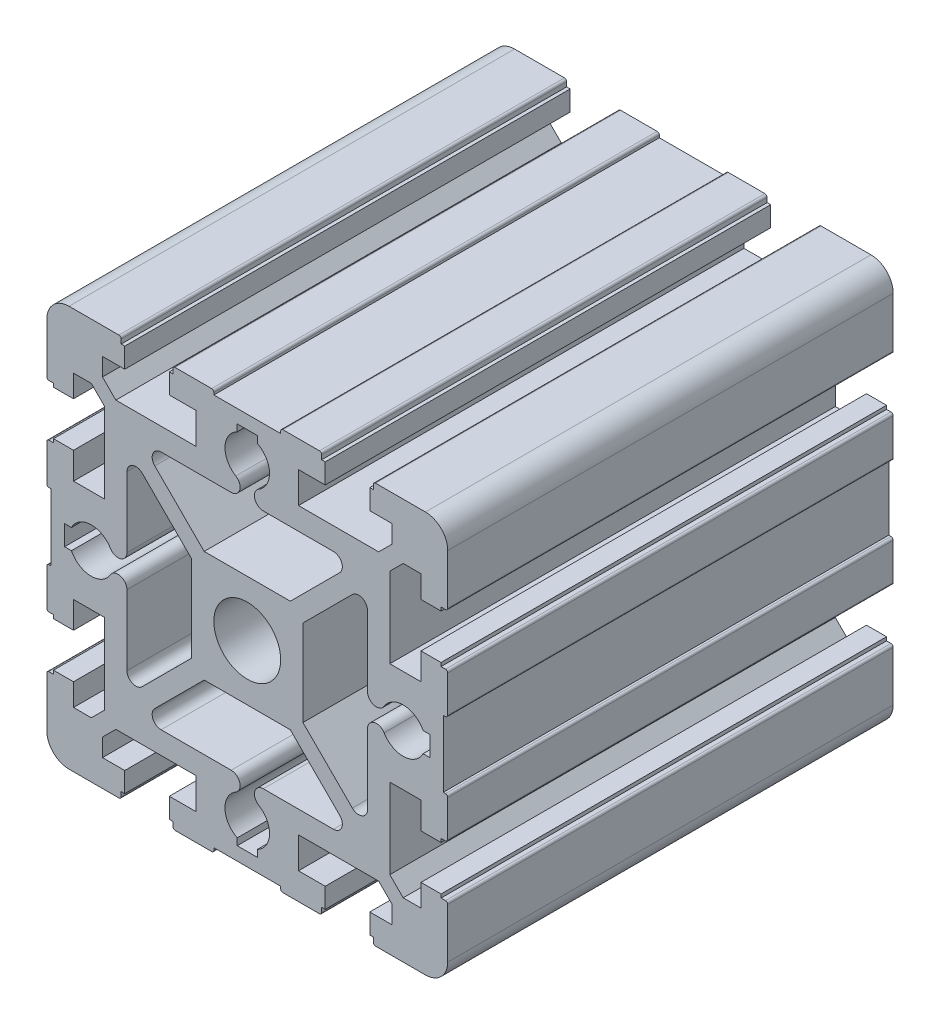
from build123d import *

# Parameters (mm, degrees)
SKETCH1_R          = 7.5
BASE_EXTRUDE_DEPTH = 100


with BuildPart() as part:
    # Sketch1 → Base-Extrude (new body)
    with BuildSketch(Plane.XY):
        with BuildLine():
            Line((16.6998736, -44.500001), (16.6998736, -43.50001))
            Line((16.6998736, -43.50001), (17.499871, -43.50001))
            Line((17.499871, -43.50001), (17.499871, -39.000019))
            Line((17.499871, -39.000019), (11.499883, -39.000019))
            Line((11.499883, -39.000019), (11.499883, -32.000033))
            Line((11.499883, -32.000033), (29.499851, -32.000033))
            Line((29.499851, -32.000033), (32.499845, -35.000027))
            Line((32.499845, -35.000027), (32.499845, -39.000018))
            Line((32.499845, -39.000018), (27.500035, -39.000018))
            Line((27.500035, -39.000018), (27.500035, -43.500009))
            Line((27.500035, -43.500009), (28.3000284, -43.500009))
            Line((28.3000284, -43.500009), (28.3000284, -44.500001))
            ThreePointArc((28.3000284, -44.500001), (28.446474607, -44.853553793), (28.8000274, -45))
            Line((28.8000274, -45), (40.000013735, -45))
            ThreePointArc((40.000013735, -45), (43.535537929, -43.535537929), (45, -40.000013735))
            Line((45, -40.000013735), (45, -28.7999394))
            ThreePointArc((45, -28.7999394), (44.853553793, -28.446386607), (44.500001, -28.2999404))
            Line((44.500001, -28.2999404), (43.500011, -28.2999404))
            Line((43.500011, -28.2999404), (43.500011, -27.499943))
            Line((43.500011, -27.499943), (39.00002, -27.499943))
            Line((39.00002, -27.499943), (39.00002, -32.499933))
            Line((39.00002, -32.499933), (35.000028, -32.499933))
            Line((35.000028, -32.499933), (32.000034, -29.499939))
            Line((32.000034, -29.499939), (32.000034, -11.499973))
            Line((32.000034, -11.499973), (39.00002, -11.499973))
            Line((39.00002, -11.499973), (39.00002, -17.499963))
            Line((39.00002, -17.499963), (43.500011, -17.499963))
            Line((43.500011, -17.499963), (43.500011, -16.6999656))
            Line((43.500011, -16.6999656), (44.500001, -16.6999656))
            ThreePointArc((44.500001, -16.6999656), (44.853553793, -16.553519393), (45, -16.1999666))
            Line((45, -16.1999666), (45, -7.999988))
            ThreePointArc((45, -7.999988), (44.853553793, -7.646435207), (44.500001, -7.499989))
            Line((44.500001, -7.499989), (44.000002, -7.499989))
            Line((44.000002, -7.499989), (44.000002, 7.499981))
            Line((44.000002, 7.499981), (44.500001, 7.499981))
            ThreePointArc((44.500001, 7.499981), (44.853553793, 7.646427207), (45, 7.99998))
            Line((45, 7.99998), (45, 16.1999646))
            ThreePointArc((45, 16.1999646), (44.853553793, 16.553517393), (44.500001, 16.6999636))
            Line((44.500001, 16.6999636), (43.500011, 16.6999636))
            Line((43.500011, 16.6999636), (43.500011, 17.499961))
            Line((43.500011, 17.499961), (39.00002, 17.499961))
            Line((39.00002, 17.499961), (39.00002, 11.499973))
            Line((39.00002, 11.499973), (32.000034, 11.499973))
            Line((32.000034, 11.499973), (32.000034, 29.499941))
            Line((32.000034, 29.499941), (35.000028, 32.499935))
            Line((35.000028, 32.499935), (39.00002, 32.499935))
            Line((39.00002, 32.499935), (39.00002, 27.499945))
            Line((39.00002, 27.499945), (43.500011, 27.499945))
            Line((43.500011, 27.499945), (43.500011, 28.2999384))
            Line((43.500011, 28.2999384), (44.500001, 28.2999384))
            ThreePointArc((44.500001, 28.2999384), (44.853553793, 28.446384607), (45, 28.7999374))
            Line((45, 28.7999374), (45, 40.000013735))
            ThreePointArc((45, 40.000013735), (43.535537929, 43.535537929), (40.000013735, 45))
            Line((40.000013735, 45), (28.8000274, 45))
            ThreePointArc((28.8000274, 45), (28.446474607, 44.853553793), (28.3000284, 44.500001))
            Line((28.3000284, 44.500001), (28.3000284, 43.500003))
            Line((28.3000284, 43.500003), (27.500035, 43.500003))
            Line((27.500035, 43.500003), (27.500035, 39.000012))
            Line((27.500035, 39.000012), (32.499863, 39.000012))
            Line((32.499863, 39.000012), (32.499863, 35.00002))
            Line((32.499863, 35.00002), (29.499869, 32.000026))
            Line((29.499869, 32.000026), (11.499901, 32.000026))
            Line((11.499901, 32.000026), (11.499901, 39.000012))
            Line((11.499901, 39.000012), (17.499893, 39.000012))
            Line((17.499893, 39.000012), (17.499893, 43.500003))
            Line((17.499893, 43.500003), (16.6998916, 43.500003))
            Line((16.6998916, 43.500003), (16.6998916, 44.500001))
            ThreePointArc((16.6998916, 44.500001), (16.553445393, 44.853553793), (16.1998926, 45))
            Line((16.1998926, 45), (7.999916, 45))
            ThreePointArc((7.999916, 45), (7.646363207, 44.853553793), (7.499917, 44.500001))
            Line((7.499917, 44.500001), (7.499917, 44.000002))
            Line((7.499917, 44.000002), (-7.500053, 44.000002))
            Line((-7.500053, 44.000002), (-7.500053, 44.500001))
            ThreePointArc((-7.500053, 44.500001), (-7.646499207, 44.853553793), (-8.000052, 45))
            Line((-8.000052, 45), (-16.2000386, 45))
            ThreePointArc((-16.2000386, 45), (-16.553591393, 44.853553793), (-16.7000376, 44.500001))
            Line((-16.7000376, 44.500001), (-16.7000376, 43.500003))
            Line((-16.7000376, 43.500003), (-17.500035, 43.500003))
            Line((-17.500035, 43.500003), (-17.500035, 39.000012))
            Line((-17.500035, 39.000012), (-11.500065, 39.000012))
            Line((-11.500065, 39.000012), (-11.500065, 32.000026))
            Line((-11.500065, 32.000026), (-29.500031, 32.000026))
            Line((-29.500031, 32.000026), (-32.500025, 35.00002))
            Line((-32.500025, 35.00002), (-32.500025, 39.000012))
            Line((-32.500025, 39.000012), (-27.500035, 39.000012))
            Line((-27.500035, 39.000012), (-27.500035, 43.500003))
            Line((-27.500035, 43.500003), (-28.3000324, 43.500003))
            Line((-28.3000324, 43.500003), (-28.3000324, 44.500001))
            ThreePointArc((-28.3000324, 44.500001), (-28.446478607, 44.853553793), (-28.8000314, 45))
            Line((-28.8000314, 45), (-40.000013735, 45))
            ThreePointArc((-40.000013735, 45), (-43.535537929, 43.535537929), (-45, 40.000013735))
            Line((-45, 40.000013735), (-45, 28.7999374))
            ThreePointArc((-45, 28.7999374), (-44.853553793, 28.446384607), (-44.500001, 28.2999384))
            Line((-44.500001, 28.2999384), (-43.500013, 28.2999384))
            Line((-43.500013, 28.2999384), (-43.500013, 27.499945))
            Line((-43.500013, 27.499945), (-39.000022, 27.499945))
            Line((-39.000022, 27.499945), (-39.000022, 32.499935))
            Line((-39.000022, 32.499935), (-35.00003, 32.499935))
            Line((-35.00003, 32.499935), (-32.000036, 29.499941))
            Line((-32.000036, 29.499941), (-32.000036, 11.499973))
            Line((-32.000036, 11.499973), (-39.000021, 11.499973))
            Line((-39.000021, 11.499973), (-39.000021, 17.499965))
            Line((-39.000021, 17.499965), (-43.500012, 17.499965))
            Line((-43.500012, 17.499965), (-43.500012, 16.6999676))
            Line((-43.500012, 16.6999676), (-44.500001, 16.6999676))
            ThreePointArc((-44.500001, 16.6999676), (-44.853553793, 16.553521393), (-45, 16.1999686))
            Line((-45, 16.1999686), (-45, 7.999984))
            ThreePointArc((-45, 7.999984), (-44.853553793, 7.646431207), (-44.500001, 7.499985))
            Line((-44.500001, 7.499985), (-44.000002, 7.499985))
            Line((-44.000002, 7.499985), (-44.000002, -7.499985))
            Line((-44.000002, -7.499985), (-44.500001, -7.499985))
            ThreePointArc((-44.500001, -7.499985), (-44.853553793, -7.646431207), (-45, -7.999984))
            Line((-45, -7.999984), (-45, -16.1999666))
            ThreePointArc((-45, -16.1999666), (-44.853553793, -16.553519393), (-44.500001, -16.6999656))
            Line((-44.500001, -16.6999656), (-43.500012, -16.6999656))
            Line((-43.500012, -16.6999656), (-43.500012, -17.499963))
            Line((-43.500012, -17.499963), (-39.000021, -17.499963))
            Line((-39.000021, -17.499963), (-39.000021, -11.499973))
            Line((-39.000021, -11.499973), (-32.000034, -11.499973))
            Line((-32.000034, -11.499973), (-32.000034, -29.499939))
            Line((-32.000034, -29.499939), (-35.000028, -32.499933))
            Line((-35.000028, -32.499933), (-39.00002, -32.499933))
            Line((-39.00002, -32.499933), (-39.00002, -27.499943))
            Line((-39.00002, -27.499943), (-43.500011, -27.499943))
            Line((-43.500011, -27.499943), (-43.500011, -28.2999404))
            Line((-43.500011, -28.2999404), (-44.500001, -28.2999404))
            ThreePointArc((-44.500001, -28.2999404), (-44.853553793, -28.446386607), (-45, -28.7999394))
            Line((-45, -28.7999394), (-45, -40.000013735))
            ThreePointArc((-45, -40.000013735), (-43.535537929, -43.535537929), (-40.000013735, -45))
            Line((-40.000013735, -45), (-28.8000294, -45))
            ThreePointArc((-28.8000294, -45), (-28.446476607, -44.853553793), (-28.3000304, -44.500001))
            Line((-28.3000304, -44.500001), (-28.3000304, -43.500011))
            Line((-28.3000304, -43.500011), (-27.500033, -43.500011))
            Line((-27.500033, -43.500011), (-27.500033, -38.999986))
            Line((-27.500033, -38.999986), (-32.500023, -38.999986))
            Line((-32.500023, -38.999986), (-32.500023, -34.999994))
            Line((-32.500023, -34.999994), (-29.500029, -32))
            Line((-29.500029, -32), (-11.500063, -32))
            Line((-11.500063, -32), (-11.500063, -39.000019))
            Line((-11.500063, -39.000019), (-17.500053, -39.000019))
            Line((-17.500053, -39.000019), (-17.500053, -43.50001))
            Line((-17.500053, -43.50001), (-16.7000556, -43.50001))
            Line((-16.7000556, -43.50001), (-16.7000556, -44.500001))
            ThreePointArc((-16.7000556, -44.500001), (-16.553609393, -44.853553793), (-16.2000566, -45))
            Line((-16.2000566, -45), (-8.000074, -45))
            ThreePointArc((-8.000074, -45), (-7.646521207, -44.853553793), (-7.500075, -44.500001))
            Line((-7.500075, -44.500001), (-7.500075, -44.000002))
            Line((-7.500075, -44.000002), (7.499895, -44.000002))
            Line((7.499895, -44.000002), (7.499895, -44.500001))
            ThreePointArc((7.499895, -44.500001), (7.646341207, -44.853553793), (7.999894, -45))
            Line((7.999894, -45), (16.1998746, -45))
            ThreePointArc((16.1998746, -45), (16.553427393, -44.853553793), (16.6998736, -44.500001))
        make_face()
        Circle(SKETCH1_R, mode=Mode.SUBTRACT)
        with BuildLine():
            Line((12.499986, -9.671543771), (23.585745828, -20.7573136))
            ThreePointArc((23.585745828, -20.7573136), (25.765322015, -21.190860615), (26.999954, -19.343105428))
            Line((26.999954, -19.343105428), (26.999954, -3.605541903))
            ThreePointArc((26.999954, -3.605541903), (28.465428132, -1.678296578), (30.714232571, -2.575384963))
            ThreePointArc((30.714232571, -2.575384963), (35.185729521, -4.996534327), (39.465070053, -2.24999217))
            Line((39.465070053, -2.24999217), (40.999925983, -2.24999217))
            Line((40.999925983, -2.24999217), (40.999925983, 2.249997151))
            Line((40.999925983, 2.249997151), (39.465067543, 2.249997151))
            ThreePointArc((39.465067543, 2.249997151), (35.185729837, 4.996534315), (30.714235771, 2.575390287))
            ThreePointArc((30.714235771, 2.575390287), (28.465431331, 1.678301901), (26.999957199, 3.605547227))
            Line((26.999957199, 3.605547227), (26.999957199, 19.343113752))
            ThreePointArc((26.999957199, 19.343113752), (25.765326607, 21.190875562), (23.585745828, 20.757327371))
            Line((23.585745828, 20.757327371), (12.499986, 9.671557543))
            Line((12.499986, 9.671557543), (12.499986, -9.671543771))
        make_face(mode=Mode.SUBTRACT)
        with BuildLine():
            Line((-20.75732066, -23.585738106), (-9.671550831, -12.499978278))
            Line((-9.671550831, -12.499978278), (9.671550482, -12.499978278))
            Line((9.671550482, -12.499978278), (20.757320311, -23.585739106))
            ThreePointArc((20.757320311, -23.585739106), (21.190869672, -25.765312828), (19.343119387, -26.99994862))
            Line((19.343119387, -26.99994862), (3.605552862, -26.99994862))
            ThreePointArc((3.605552862, -26.99994862), (1.678307917, -28.465422253), (2.575395922, -30.714226192))
            ThreePointArc((2.575395922, -30.714226192), (4.99654532, -35.185730085), (2.250002144, -39.465077238))
            Line((2.250002144, -39.465077238), (2.250002144, -40.999931911))
            Line((2.250002144, -40.999931911), (-2.250002653, -40.999931911))
            Line((-2.250002653, -40.999931911), (-2.250002653, -39.465076981))
            ThreePointArc((-2.250002653, -39.465076981), (-4.996545415, -35.185727527), (-2.575392024, -30.714223849))
            ThreePointArc((-2.575392024, -30.714223849), (-1.678304018, -28.46541991), (-3.605548963, -26.999946278))
            Line((-3.605548963, -26.999946278), (-19.343112488, -26.999946278))
            ThreePointArc((-19.343112488, -26.999946278), (-21.190867675, -25.765314293), (-20.75732066, -23.585738106))
        make_face(mode=Mode.SUBTRACT)
        with BuildLine():
            Line((9.671538727, 12.499978278), (20.757308556, 23.585738106))
            ThreePointArc((20.757308556, 23.585738106), (21.190856386, 25.76530783), (19.343112754, 26.999945984))
            Line((19.343112754, 26.999945984), (3.605553229, 26.999945984))
            ThreePointArc((3.605553229, 26.999945984), (1.678307904, 28.465420116), (2.57539629, 30.714224555))
            ThreePointArc((2.57539629, 30.714224555), (4.99654693, 35.185729616), (2.250003332, 39.465078422))
            Line((2.250003332, 39.465078422), (2.250003332, 40.999934609))
            Line((2.250003332, 40.999934609), (-2.250002822, 40.999934609))
            Line((-2.250002822, 40.999934609), (-2.250002822, 39.465078678))
            ThreePointArc((-2.250002822, 39.465078678), (-4.996546909, 35.185730186), (-2.575396779, 30.714224849))
            ThreePointArc((-2.575396779, 30.714224849), (-1.678308393, 28.46542041), (-3.605553718, 26.999946278))
            Line((-3.605553718, 26.999946278), (-19.343120243, 26.999946278))
            ThreePointArc((-19.343120243, 26.999946278), (-21.19087643, 25.765314961), (-20.757330415, 23.585738106))
            Line((-20.757330415, 23.585738106), (-9.671562586, 12.499978278))
            Line((-9.671562586, 12.499978278), (9.671538727, 12.499978278))
        make_face(mode=Mode.SUBTRACT)
        with BuildLine():
            Line((-12.499986, -9.671543771), (-23.585745828, -20.7573136))
            ThreePointArc((-23.585745828, -20.7573136), (-25.765322015, -21.190860615), (-26.999954, -19.343105428))
            Line((-26.999954, -19.343105428), (-26.999954, -3.605541903))
            ThreePointArc((-26.999954, -3.605541903), (-28.465428132, -1.678296578), (-30.714232571, -2.575384963))
            ThreePointArc((-30.714232571, -2.575384963), (-35.185729521, -4.996534327), (-39.465070053, -2.24999217))
            Line((-39.465070053, -2.24999217), (-40.999925983, -2.24999217))
            Line((-40.999925983, -2.24999217), (-40.999925983, 2.249997151))
            Line((-40.999925983, 2.249997151), (-39.465067543, 2.249997151))
            ThreePointArc((-39.465067543, 2.249997151), (-35.185729837, 4.996534315), (-30.714235771, 2.575390287))
            ThreePointArc((-30.714235771, 2.575390287), (-28.465431331, 1.678301901), (-26.999957199, 3.605547227))
            Line((-26.999957199, 3.605547227), (-26.999957199, 19.343113752))
            ThreePointArc((-26.999957199, 19.343113752), (-25.765326607, 21.190875562), (-23.585745828, 20.757327371))
            Line((-23.585745828, 20.757327371), (-12.499986, 9.671557543))
            Line((-12.499986, 9.671557543), (-12.499986, -9.671543771))
        make_face(mode=Mode.SUBTRACT)
    extrude(amount=-BASE_EXTRUDE_DEPTH)


solid = part.part
